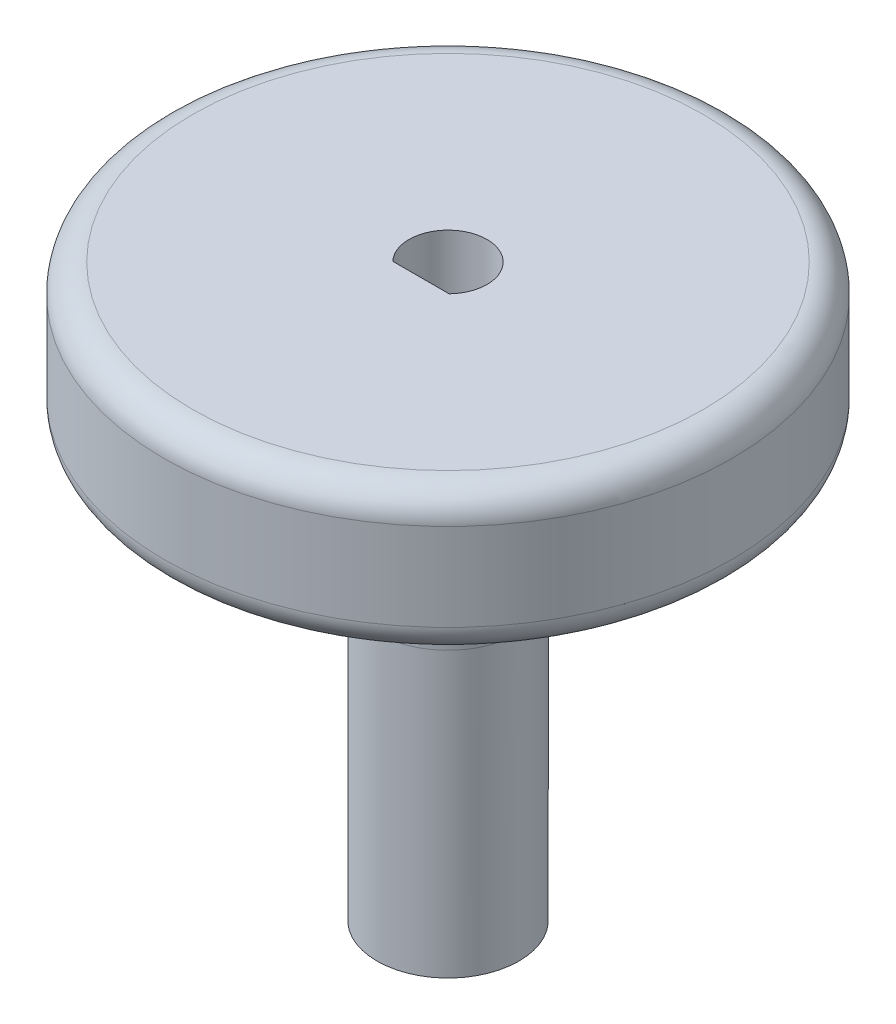
from build123d import *

# Parameters (mm, degrees)
SKETCH1_R           = 20
BOSS_EXTRUDE1_DEPTH = 10.16
SKETCH3_R           = 5
BOSS_EXTRUDE3_DEPTH = 30
CUT_EXTRUDE1_DEPTH  = 40.16
FILLET1_R           = 10
FILLET2_R           = 2


with BuildPart() as part:
    # Sketch1 → Boss-Extrude1 (new body)
    with BuildSketch(Plane(origin=(0, 0, 0), x_dir=(1, 0, 0), z_dir=(0, 1, 0))):
        Circle(SKETCH1_R)
    extrude(amount=BOSS_EXTRUDE1_DEPTH)

    # Sketch3 → Boss-Extrude3 (add)
    with BuildSketch(Plane.XZ):
        Circle(SKETCH3_R)
    extrude(amount=BOSS_EXTRUDE3_DEPTH)

    # Sketch5 → Cut-Extrude1 (cut)
    with BuildSketch(Plane.XZ.offset(30)):
        with BuildLine():
            Line((-1.983299019, 1.905), (1.983299019, 1.905))
            ThreePointArc((1.983299019, 1.905), (0, -2.75), (-1.983299019, 1.905))
        make_face()
    extrude(amount=-CUT_EXTRUDE1_DEPTH, mode=Mode.SUBTRACT)

    # Fillet1
    fillet1_edges = [part.edges().sort_by_distance(p)[0] for p in [
        (-5, 0, 0),
    ]]
    fillet(fillet1_edges, radius=FILLET1_R)

    # Fillet2
    fillet2_edges = [part.edges().sort_by_distance(p)[0] for p in [
        (-20, 0, 0),
        (-20, 10.16, 0),
    ]]
    fillet(fillet2_edges, radius=FILLET2_R)


solid = part.part
